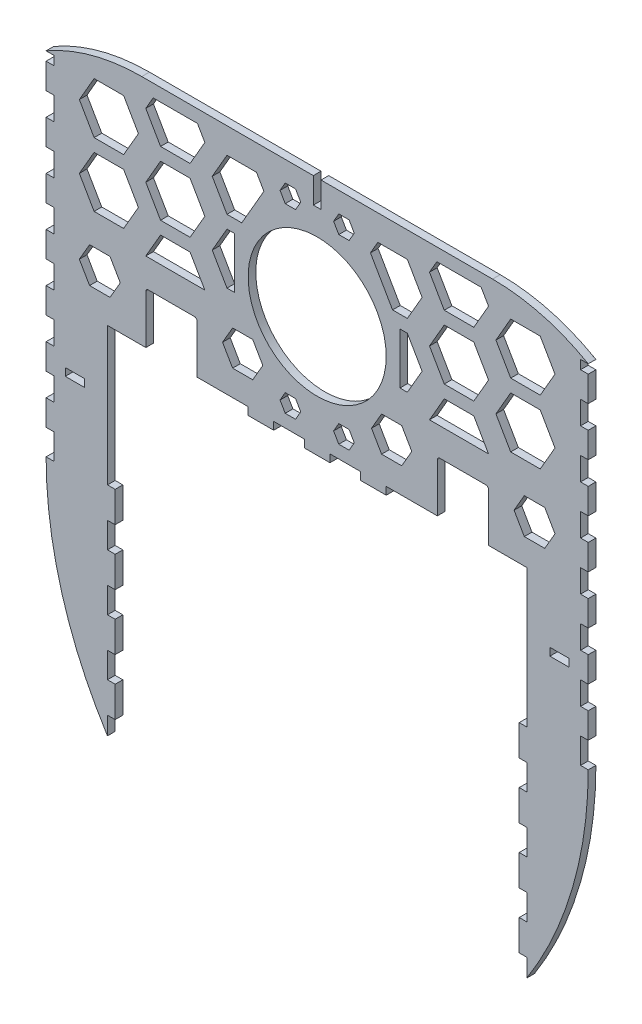
from build123d import *

# Parameters (mm, degrees)
SKETCH1_R           = 27
BOSS_EXTRUDE1_DEPTH = 3
SKETCH2_W           = 7.5
SKETCH2_H           = 3
SKETCH2_W_2         = 3
SKETCH2_H_2         = 10
CUT_EXTRUDE1_DEPTH  = 3
CUT_EXTRUDE2_DEPTH  = 4


with BuildPart() as part:
    # Sketch1 → Boss-Extrude1 (new body)
    with BuildSketch(Plane.XY):
        with BuildLine():
            Line((-79, 17.213436382), (-82, 17.213436382))
            Line((-82, 17.213436382), (-82, 71.213436382))
            Line((-82, 71.213436382), (-67, 71.213436382))
            Line((-67, 71.213436382), (-67, 90.213436382))
            ThreePointArc((-67, 90.213436382), (-66.707106781, 90.920543163), (-66, 91.213436382))
            Line((-66, 91.213436382), (-48, 91.213436382))
            ThreePointArc((-48, 91.213436382), (-47.292893219, 90.920543163), (-47, 90.213436382))
            Line((-47, 90.213436382), (-47, 71.213436382))
            Line((-47, 71.213436382), (-27, 71.213436382))
            Line((-27, 71.213436382), (-27, 68.213436382))
            Line((-27, 68.213436382), (-17, 68.213436382))
            Line((-17, 68.213436382), (-17, 71.213436382))
            Line((-17, 71.213436382), (-5, 71.213436382))
            Line((-5, 71.213436382), (-5, 68.213436382))
            Line((-5, 68.213436382), (5, 68.213436382))
            Line((5, 68.213436382), (5, 71.213436382))
            Line((5, 71.213436382), (17, 71.213436382))
            Line((17, 71.213436382), (17, 68.213436382))
            Line((17, 68.213436382), (27, 68.213436382))
            Line((27, 68.213436382), (27, 71.213436382))
            Line((27, 71.213436382), (47, 71.213436382))
            Line((47, 71.213436382), (47, 90.213436382))
            ThreePointArc((47, 90.213436382), (47.292893219, 90.920543163), (48, 91.213436382))
            Line((48, 91.213436382), (66, 91.213436382))
            ThreePointArc((66, 91.213436382), (66.707106781, 90.920543163), (67, 90.213436382))
            Line((67, 90.213436382), (67, 71.213436382))
            Line((67, 71.213436382), (82, 71.213436382))
            Line((82, 71.213436382), (82, 17.213436382))
            Line((82, 17.213436382), (79, 17.213436382))
            Line((79, 17.213436382), (79, 5.213436382))
            Line((79, 5.213436382), (82, 5.213436382))
            Line((82, 5.213436382), (82, -4.786563618))
            Line((82, -4.786563618), (79, -4.786563618))
            Line((79, -4.786563618), (79, -16.786563618))
            Line((79, -16.786563618), (82, -16.786563618))
            Line((82, -16.786563618), (82, -26.786563618))
            Line((82, -26.786563618), (79, -26.786563618))
            Line((79, -26.786563618), (79, -38.786563618))
            Line((79, -38.786563618), (82, -38.786563618))
            Line((82, -38.786563618), (82, -48.786563618))
            Line((82, -48.786563618), (79, -48.786563618))
            Line((79, -48.786563618), (79, -60.786563618))
            Line((79, -60.786563618), (82, -60.786563618))
            Line((82, -60.786563618), (82, -67.786563618))
            ThreePointArc((82, -67.786563618), (99.878161007, -28.246574093), (106, 14.713436382))
            Line((106, 14.713436382), (103, 14.713436382))
            Line((103, 14.713436382), (103, 24.713436382))
            Line((103, 24.713436382), (106, 24.713436382))
            Line((106, 24.713436382), (106, 34.713436382))
            Line((106, 34.713436382), (103, 34.713436382))
            Line((103, 34.713436382), (103, 43.713436382))
            Line((103, 43.713436382), (106, 43.713436382))
            Line((106, 43.713436382), (106, 53.713436382))
            Line((106, 53.713436382), (103, 53.713436382))
            Line((103, 53.713436382), (103, 62.713436382))
            Line((103, 62.713436382), (106, 62.713436382))
            Line((106, 62.713436382), (106, 72.713436382))
            Line((106, 72.713436382), (103, 72.713436382))
            Line((103, 72.713436382), (103, 81.713436382))
            Line((103, 81.713436382), (106, 81.713436382))
            Line((106, 81.713436382), (106, 91.713436382))
            Line((106, 91.713436382), (103, 91.713436382))
            Line((103, 91.713436382), (103, 100.713436382))
            Line((103, 100.713436382), (106, 100.713436382))
            Line((106, 100.713436382), (106, 110.713436382))
            Line((106, 110.713436382), (103, 110.713436382))
            Line((103, 110.713436382), (103, 119.713436382))
            Line((103, 119.713436382), (106, 119.713436382))
            Line((106, 119.713436382), (106, 129.713436382))
            Line((106, 129.713436382), (103, 129.713436382))
            Line((103, 129.713436382), (103, 138.713436382))
            Line((103, 138.713436382), (106, 138.713436382))
            Line((106, 138.713436382), (106, 148.713436382))
            Line((106, 148.713436382), (103, 148.713436382))
            Line((103, 148.713436382), (103, 152.213436382))
            Line((103, 152.213436382), (106, 152.213436382))
            ThreePointArc((106, 152.213436382), (87.948342863, 159.670320113), (68.583426132, 162.213436382))
            Line((68.583426132, 162.213436382), (-68.583426132, 162.213436382))
            ThreePointArc((-68.583426132, 162.213436382), (-87.948342863, 159.670320113), (-106, 152.213436382))
            Line((-106, 152.213436382), (-103, 152.213436382))
            Line((-103, 152.213436382), (-103, 148.713436382))
            Line((-103, 148.713436382), (-106, 148.713436382))
            Line((-106, 148.713436382), (-106, 138.713436382))
            Line((-106, 138.713436382), (-103, 138.713436382))
            Line((-103, 138.713436382), (-103, 129.713436382))
            Line((-103, 129.713436382), (-106, 129.713436382))
            Line((-106, 129.713436382), (-106, 119.713436382))
            Line((-106, 119.713436382), (-103, 119.713436382))
            Line((-103, 119.713436382), (-103, 110.713436382))
            Line((-103, 110.713436382), (-106, 110.713436382))
            Line((-106, 110.713436382), (-106, 100.713436382))
            Line((-106, 100.713436382), (-103, 100.713436382))
            Line((-103, 100.713436382), (-103, 91.713436382))
            Line((-103, 91.713436382), (-106, 91.713436382))
            Line((-106, 91.713436382), (-106, 81.713436382))
            Line((-106, 81.713436382), (-103, 81.713436382))
            Line((-103, 81.713436382), (-103, 72.713436382))
            Line((-103, 72.713436382), (-106, 72.713436382))
            Line((-106, 72.713436382), (-106, 62.713436382))
            Line((-106, 62.713436382), (-103, 62.713436382))
            Line((-103, 62.713436382), (-103, 53.713436382))
            Line((-103, 53.713436382), (-106, 53.713436382))
            Line((-106, 53.713436382), (-106, 43.713436382))
            Line((-106, 43.713436382), (-103, 43.713436382))
            Line((-103, 43.713436382), (-103, 34.713436382))
            Line((-103, 34.713436382), (-106, 34.713436382))
            Line((-106, 34.713436382), (-106, 24.713436382))
            Line((-106, 24.713436382), (-103, 24.713436382))
            Line((-103, 24.713436382), (-103, 14.713436382))
            Line((-103, 14.713436382), (-106, 14.713436382))
            ThreePointArc((-106, 14.713436382), (-99.878161007, -28.246574093), (-82, -67.786563618))
            Line((-82, -67.786563618), (-82, -60.786563618))
            Line((-82, -60.786563618), (-79, -60.786563618))
            Line((-79, -60.786563618), (-79, -48.786563618))
            Line((-79, -48.786563618), (-82, -48.786563618))
            Line((-82, -48.786563618), (-82, -38.786563618))
            Line((-82, -38.786563618), (-79, -38.786563618))
            Line((-79, -38.786563618), (-79, -26.786563618))
            Line((-79, -26.786563618), (-82, -26.786563618))
            Line((-82, -26.786563618), (-82, -16.786563618))
            Line((-82, -16.786563618), (-79, -16.786563618))
            Line((-79, -16.786563618), (-79, -4.786563618))
            Line((-79, -4.786563618), (-82, -4.786563618))
            Line((-82, -4.786563618), (-82, 5.213436382))
            Line((-82, 5.213436382), (-79, 5.213436382))
            Line((-79, 5.213436382), (-79, 17.213436382))
        make_face()
        with Locations((0, 115.213436382)):
            Circle(SKETCH1_R, mode=Mode.SUBTRACT)
    extrude(amount=BOSS_EXTRUDE1_DEPTH)

    # Sketch2 → Cut-Extrude1 (cut)
    with BuildSketch(Plane.XY.offset(3)):
        with Locations((-94.75, 47.213436382)):
            Rectangle(SKETCH2_W, SKETCH2_H)
        with Locations((0, 157.213436382)):
            Rectangle(SKETCH2_W_2, SKETCH2_H_2)
        with Locations((94.75, 47.213436382)):
            Rectangle(SKETCH2_W, SKETCH2_H)
    extrude(amount=-CUT_EXTRUDE1_DEPTH, mode=Mode.SUBTRACT)

    # Sketch3 → Cut-Extrude2 (cut, through all)
    with BuildSketch(Plane.XY.offset(3)):
        Polygon((-69.905989232, 142.213436382), (-75.679491924, 152.213436382), (-87.226497308, 152.213436382), (-93, 142.213436382), (-87.226497308, 132.213436382), (-75.679491924, 132.213436382), align=None)
        Polygon((-43.925227119, 127.213436382), (-49.698729811, 137.213436382), (-61.245735195, 137.213436382), (-67.019237886, 127.213436382), (-61.245735195, 117.213436382), (-49.698729811, 117.213436382), align=None)
        Polygon((-20.831216351, 147.213436382), (-23.717967697, 152.213436382), (-35.264973081, 152.213436382), (-41.038475773, 142.213436382), (-35.264973081, 132.213436382), (-29.491470389, 132.213436382), align=None)
        Polygon((-43.925227119, 152.213436382), (-46.811978465, 157.213436382), (-64.132486541, 157.213436382), (-67.019237886, 152.213436382), (-61.245735195, 142.213436382), (-49.698729811, 142.213436382), align=None)
        Polygon((-43.925227119, 102.213436382), (-49.698729811, 112.213436382), (-61.245735195, 112.213436382), (-67.019237886, 102.213436382), align=None)
        Polygon((-35.264973081, 107.213436382), (-32.378221735, 107.213436382), (-32.378221735, 127.213436382), (-35.264973081, 127.213436382), (-41.038475773, 117.213436382), align=None)
        Polygon((-87.226497308, 107.213436382), (-75.679491924, 107.213436382), (-69.905989232, 117.213436382), (-75.679491924, 127.213436382), (-87.226497308, 127.213436382), (-93, 117.213436382), align=None)
        Polygon((-77, 88.141639613), (-81, 95.069842843), (-89, 95.069842843), (-93, 88.141639613), (-89, 81.213436382), (-81, 81.213436382), align=None)
        Polygon((-21.256406461, 88.030612358), (-25.192304845, 94.847788334), (-33.064101615, 94.847788334), (-37, 88.030612358), (-33.064101615, 81.213436382), (-25.192304845, 81.213436382), align=None)
        Polygon((-6.428421097, 79.713436382), (-8.449147039, 83.213436382), (-12.490598923, 83.213436382), (-14.511324865, 79.713436382), (-12.490598923, 76.213436382), (-8.449147039, 76.213436382), align=None)
        Polygon((-8.449147039, 154.213436382), (-6.428421097, 150.713436382), (-8.449147039, 147.213436382), (-12.490598923, 147.213436382), (-14.511324865, 150.713436382), (-12.490598923, 154.213436382), align=None)
        Polygon((6.428421097, 150.713436382), (8.449147039, 147.213436382), (12.490598923, 147.213436382), (14.511324865, 150.713436382), (12.490598923, 154.213436382), (8.449147039, 154.213436382), align=None)
        Polygon((8.449147039, 76.213436382), (6.428421097, 79.713436382), (8.449147039, 83.213436382), (12.490598923, 83.213436382), (14.511324865, 79.713436382), (12.490598923, 76.213436382), align=None)
        Polygon((25.192304845, 81.213436382), (21.256406461, 88.030612358), (25.192304845, 94.847788334), (33.064101615, 94.847788334), (37, 88.030612358), (33.064101615, 81.213436382), align=None)
        Polygon((81, 81.213436382), (77, 88.141639613), (81, 95.069842843), (89, 95.069842843), (93, 88.141639613), (89, 81.213436382), align=None)
        Polygon((20.831216351, 147.213436382), (29.491470389, 132.213436382), (35.264973081, 132.213436382), (41.038475773, 142.213436382), (35.264973081, 152.213436382), (23.717967697, 152.213436382), align=None)
        Polygon((93, 117.213436382), (87.226497308, 107.213436382), (75.679491924, 107.213436382), (69.905989232, 117.213436382), (75.679491924, 127.213436382), (87.226497308, 127.213436382), align=None)
        Polygon((41.038475773, 117.213436382), (35.264973081, 107.213436382), (32.378221735, 107.213436382), (32.378221735, 127.213436382), (35.264973081, 127.213436382), align=None)
        Polygon((61.245735195, 112.213436382), (67.019237886, 102.213436382), (43.925227119, 102.213436382), (49.698729811, 112.213436382), align=None)
        Polygon((64.132486541, 157.213436382), (46.811978465, 157.213436382), (43.925227119, 152.213436382), (49.698729811, 142.213436382), (61.245735195, 142.213436382), (67.019237886, 152.213436382), align=None)
        Polygon((49.698729811, 117.213436382), (43.925227119, 127.213436382), (49.698729811, 137.213436382), (61.245735195, 137.213436382), (67.019237886, 127.213436382), (61.245735195, 117.213436382), align=None)
        Polygon((75.679491924, 132.213436382), (69.905989232, 142.213436382), (75.679491924, 152.213436382), (87.226497308, 152.213436382), (93, 142.213436382), (87.226497308, 132.213436382), align=None)
    extrude(amount=-CUT_EXTRUDE2_DEPTH, mode=Mode.SUBTRACT)


solid = part.part
